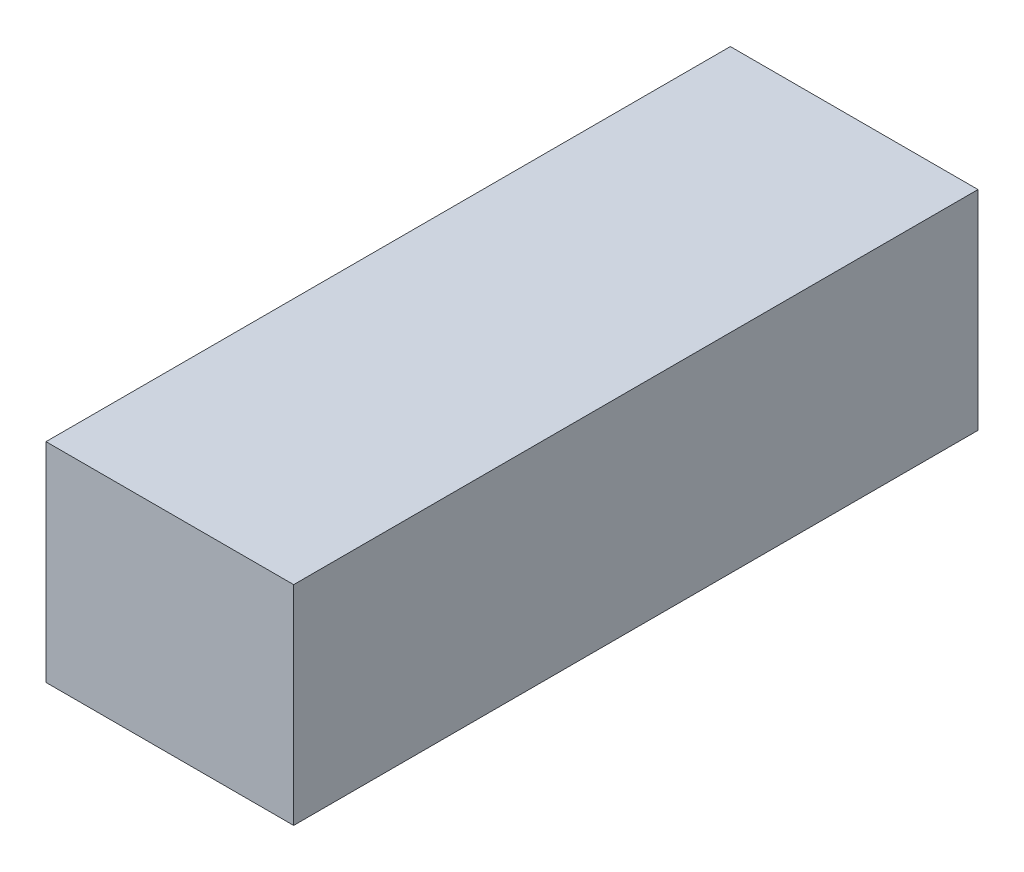
from build123d import *

# Parameters (mm, degrees)
SKETCH1_W           = 38
SKETCH1_H           = 32
BOSS_EXTRUDE1_DEPTH = 105


with BuildPart() as part:
    # Sketch1 → Boss-Extrude1 (new body)
    with BuildSketch(Plane.XY):
        with Locations((-15.59557451, 8.430164341)):
            Rectangle(SKETCH1_W, SKETCH1_H)
    extrude(amount=BOSS_EXTRUDE1_DEPTH)


solid = part.part
